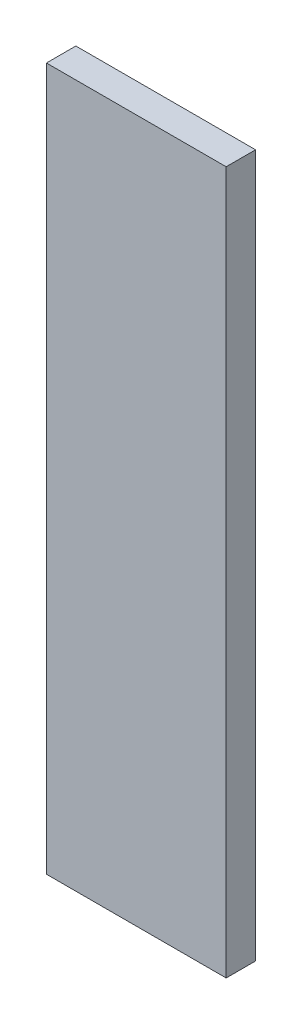
from build123d import *

# Parameters (mm, degrees)
SKETCH1_W           = 110
SKETCH1_H           = 430
BOSS_EXTRUDE1_DEPTH = 18


with BuildPart() as part:
    # Sketch1 → Boss-Extrude1 (new body)
    with BuildSketch(Plane.XY):
        Rectangle(SKETCH1_W, SKETCH1_H)
    extrude(amount=BOSS_EXTRUDE1_DEPTH)


solid = part.part
